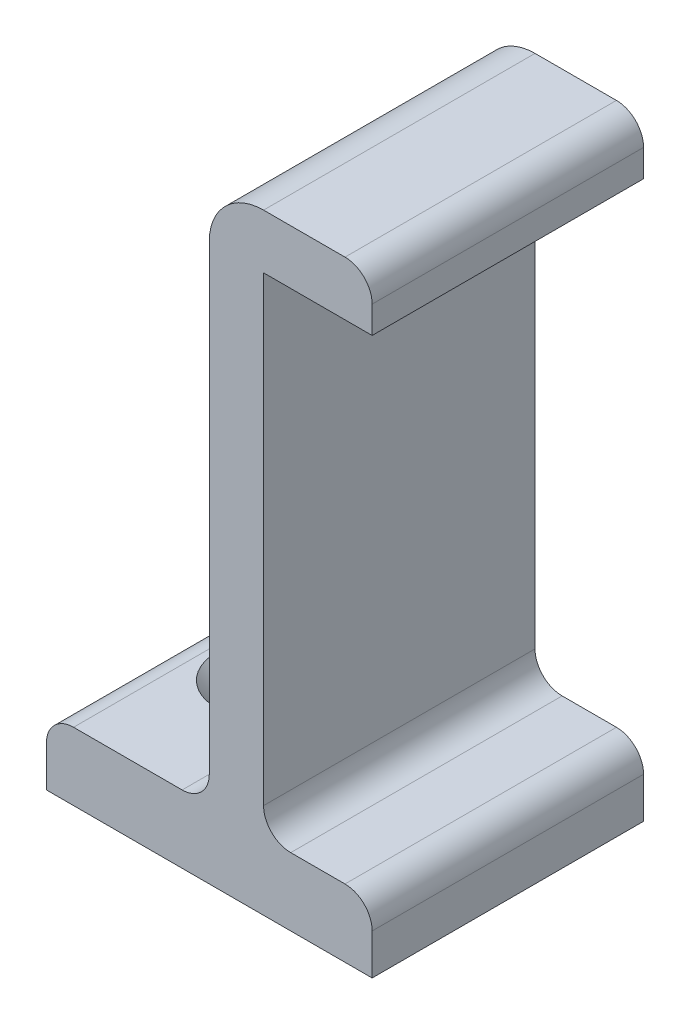
from build123d import *

# Parameters (mm, degrees)
AUFSATZ_LINEAR_AUSTRAGEN1_DEPTH = 10
SKIZZE2_R                       = 1.5
SCHNITT_LINEAR_AUSTRAGEN1_DEPTH = 6
FASE1_SIZE                      = 2
VERRUNDUNG1_R                   = 2
VERRUNDUNG2_R                   = 4


with BuildPart() as part:
    # Skizze1 → Aufsatz-Linear austragen1 (new body, symmetric)
    with BuildSketch(Plane.XY):
        Polygon((-24, 0), (0, 0), (0, 5), (-8, 5), (-8, 41), (0, 41), (0, 45), (-12, 45), (-12, 5), (-24, 5), align=None)
    extrude(amount=AUFSATZ_LINEAR_AUSTRAGEN1_DEPTH, both=True)

    # Skizze2 → Schnitt-Linear austragen1 (cut, through all)
    with BuildSketch(Plane(origin=(0, 5, 0), x_dir=(1, 0, 0), z_dir=(0, 1, 0))):
        with Locations((-18, 0)):
            Circle(SKIZZE2_R)
    extrude(amount=-SCHNITT_LINEAR_AUSTRAGEN1_DEPTH, mode=Mode.SUBTRACT)

    # Fase1
    fase1_edges = [part.edges().sort_by_distance(p)[0] for p in [
        (-19.5, 5, 0),
    ]]
    chamfer(fase1_edges, length=FASE1_SIZE)

    # Verrundung1
    verrundung1_edges = [part.edges().sort_by_distance(p)[0] for p in [
        (-24, 5, 0),
        (-12, 5, 0),
        (0, 45, 0),
        (-8, 5, 0),
        (0, 5, 0),
    ]]
    fillet(verrundung1_edges, radius=VERRUNDUNG1_R)

    # Verrundung2
    verrundung2_edges = [part.edges().sort_by_distance(p)[0] for p in [
        (-12, 45, 0),
    ]]
    fillet(verrundung2_edges, radius=VERRUNDUNG2_R)


solid = part.part
